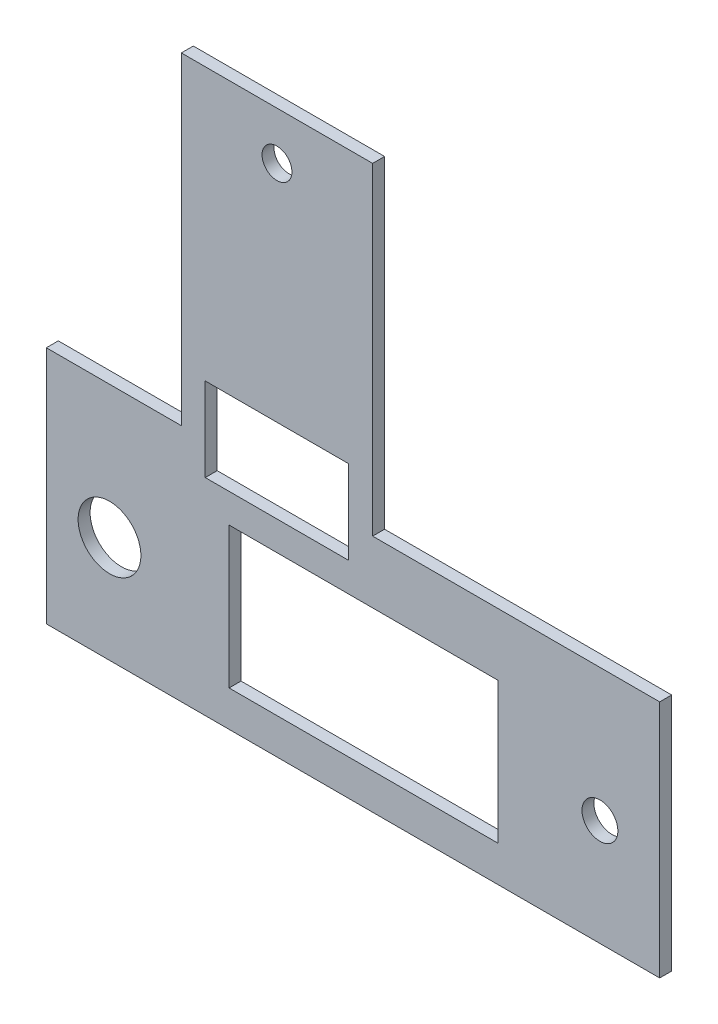
from build123d import *

# Parameters (mm, degrees)
CROQUIS1_R              = 1.25
CROQUIS1_R_2            = 2.625
CROQUIS1_R_3            = 1.5
CROQUIS1_W              = 22.5
CROQUIS1_H              = 11.8
CROQUIS1_W_2            = 12
CROQUIS1_H_2            = 7
SALIENTE_EXTRUIR1_DEPTH = 1


with BuildPart() as part:
    # Croquis1 → Saliente-Extruir1 (new body)
    with BuildSketch(Plane.XY):
        Polygon((0.682906484, 8.504854369), (0.682906484, 35.504854369), (16.682906484, 35.504854369), (16.682906484, 8.504854369), (40.690737834, 8.504854369), (40.690737834, -11.495145631), (-10.607093516, -11.495145631), (-10.607093516, 8.504854369), align=None)
        with Locations((8.682906484, 31.504854369)):
            Circle(CROQUIS1_R, mode=Mode.SUBTRACT)
        with Locations((-5.323911872, -2.595145631)):
            Circle(CROQUIS1_R_2, mode=Mode.SUBTRACT)
        with Locations((35.690737834, -2.595145631)):
            Circle(CROQUIS1_R_3, mode=Mode.SUBTRACT)
        with Locations((15.926088128, -2.595145631)):
            Rectangle(CROQUIS1_W, CROQUIS1_H, mode=Mode.SUBTRACT)
        with Locations((8.682906484, 9.246132474)):
            Rectangle(CROQUIS1_W_2, CROQUIS1_H_2, mode=Mode.SUBTRACT)
    extrude(amount=SALIENTE_EXTRUIR1_DEPTH)


solid = part.part
